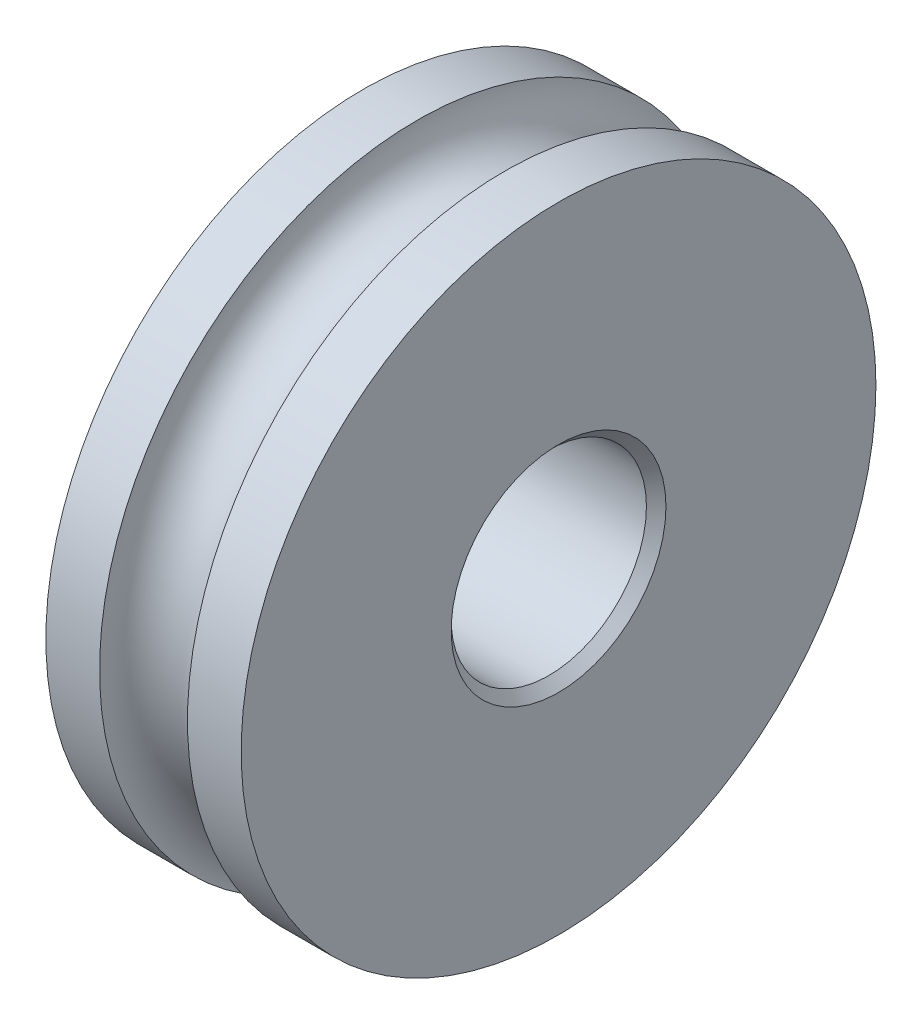
from build123d import *

# Parameters (mm, degrees)
CHAMFER_1_SIZE = 0.2


with BuildPart() as part:
    # Эскиз3 → Повернуть1 (revolve)
    with BuildSketch(Plane.XY):
        with BuildLine():
            Line((0, 2), (4, 2))
            Line((4, 2), (4, 6.5))
            Line((4, 6.5), (2.9, 6.5))
            ThreePointArc((2.9, 6.5), (2, 5.6), (1.1, 6.5))
            Line((1.1, 6.5), (0, 6.5))
            Line((0, 6.5), (0, 2))
        make_face()
    revolve(axis=Axis((7.18815516, 0, 0), (-1, 0, 0)))

    # Фаска1
    chamfer_1_edges = [part.edges().sort_by_distance(p)[0] for p in [
        (4, -2, 0),
        (0, -2, 0),
    ]]
    chamfer(chamfer_1_edges, length=CHAMFER_1_SIZE)


solid = part.part
